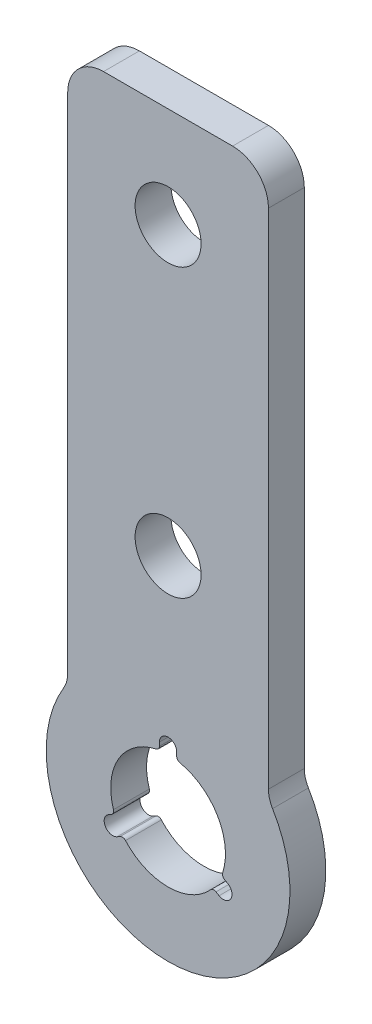
from build123d import *

# Parameters (mm, degrees)
EXTRUDE_1_DEPTH = 2.5


with BuildPart() as part:
    # 草图1 → 凸台-拉伸1 (new body)
    with BuildSketch(Plane.XY):
        with BuildLine():
            Line((7.183350415, -12.48442441), (7.183350415, 22.607248677))
            ThreePointArc((7.183350415, 22.607248677), (6.451117367, 24.37501563), (4.683350415, 25.107248677))
            Line((4.683350415, 25.107248677), (-4.316649585, 25.107248677))
            ThreePointArc((-4.316649585, 25.107248677), (-6.084416538, 24.37501563), (-6.816649585, 22.607248677))
            Line((-6.816649585, 22.607248677), (-6.816649585, -12.48442441))
            ThreePointArc((-6.816649585, -12.48442441), (-6.889401362, -13.018946893), (-7.102363871, -13.514581917))
            ThreePointArc((-7.102363871, -13.514581917), (0.183350415, -26.392751323), (7.4690647, -13.514581917))
            ThreePointArc((7.4690647, -13.514581917), (7.256102191, -13.018946893), (7.183350415, -12.48442441))
        make_face()
        with BuildLine():
            Line((4.341271874, -19.600508074), (4.124778706, -19.475515685))
            ThreePointArc((4.124778706, -19.475515685), (3.994781084, -19.323417542), (3.98933022, -19.123408756))
            ThreePointArc((3.98933022, -19.123408756), (3.64745203, -15.892751323), (1.020559717, -13.981347408))
            ThreePointArc((1.020559717, -13.981347408), (0.850072459, -13.876622428), (0.783350415, -13.687992114))
            Line((0.783350415, -13.687992114), (0.783350415, -13.438007336))
            ThreePointArc((0.783350415, -13.438007336), (0.183350415, -12.838007336), (-0.416649585, -13.438007336))
            Line((-0.416649585, -13.438007336), (-0.416649585, -13.687992114))
            ThreePointArc((-0.416649585, -13.687992114), (-0.48337163, -13.876622428), (-0.653858888, -13.981347408))
            ThreePointArc((-0.653858888, -13.981347408), (-3.280751201, -15.892751323), (-3.622629391, -19.123408756))
            ThreePointArc((-3.622629391, -19.123408756), (-3.628080255, -19.323417542), (-3.758077877, -19.475515685))
            Line((-3.758077877, -19.475515685), (-3.974571045, -19.600508074))
            ThreePointArc((-3.974571045, -19.600508074), (-4.194186288, -20.420123316), (-3.374571045, -20.639738558))
            Line((-3.374571045, -20.639738558), (-3.158077877, -20.514746169))
            ThreePointArc((-3.158077877, -20.514746169), (-2.961358211, -20.478213997), (-2.785420089, -20.573497804))
            ThreePointArc((-2.785420089, -20.573497804), (0.183350415, -21.892751323), (3.152120918, -20.573497804))
            ThreePointArc((3.152120918, -20.573497804), (3.32805904, -20.478213997), (3.524778706, -20.514746169))
            Line((3.524778706, -20.514746169), (3.741271874, -20.639738558))
            ThreePointArc((3.741271874, -20.639738558), (4.560887117, -20.420123316), (4.341271874, -19.600508074))
        make_face(mode=Mode.SUBTRACT)
        with BuildLine():
            ThreePointArc((2.483350415, -1.892751323), (0.183350415, 0.407248677), (-2.116649585, -1.892751323))
            ThreePointArc((-2.116649585, -1.892751323), (0.183350415, -4.192751323), (2.483350415, -1.892751323))
        make_face(mode=Mode.SUBTRACT)
        with BuildLine():
            ThreePointArc((2.483350415, 18.107248677), (0.183350415, 20.407248677), (-2.116649585, 18.107248677))
            ThreePointArc((-2.116649585, 18.107248677), (0.183350415, 15.807248677), (2.483350415, 18.107248677))
        make_face(mode=Mode.SUBTRACT)
    extrude(amount=EXTRUDE_1_DEPTH)


solid = part.part
